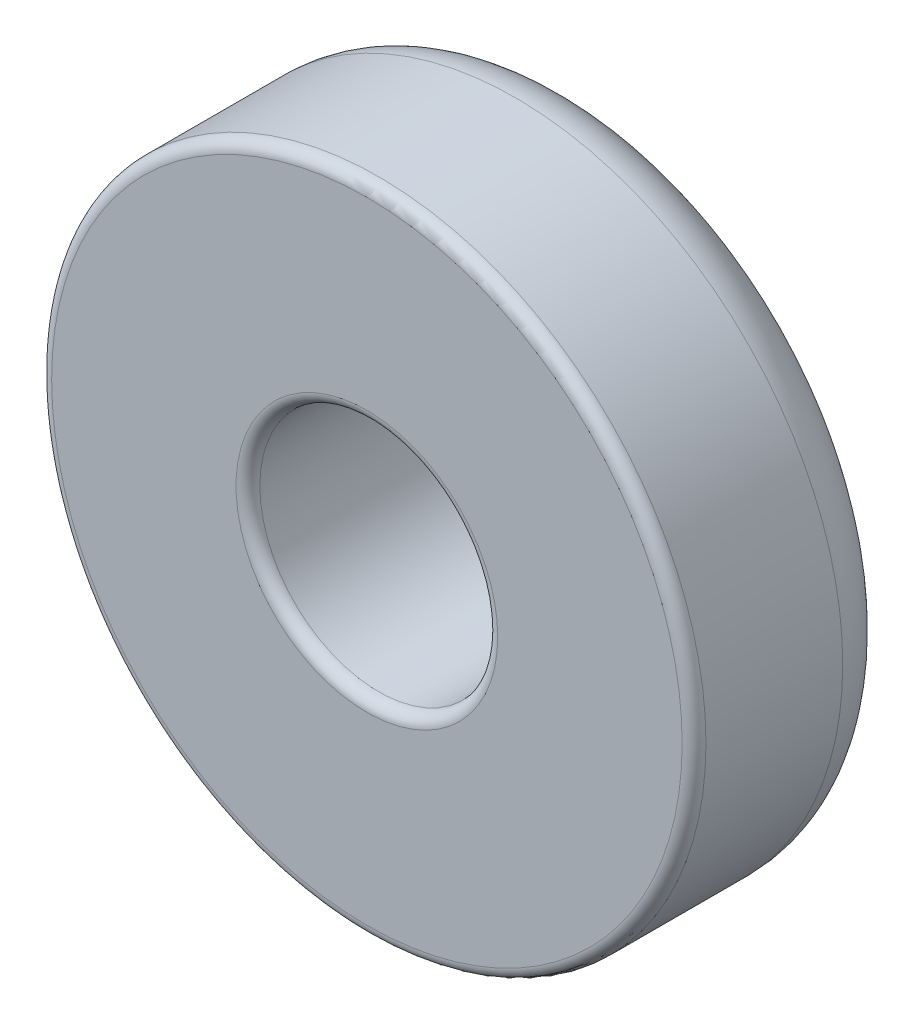
from build123d import *

# Parameters (mm, degrees)
SKETCH1_R           = 2.75
SKETCH1_R_2         = 1
EXTRUDE_THIN1_DEPTH = 1.75
FILLET1_R           = 0.5
FILLET2_R           = 0.1
FILLET3_R           = 0.1


with BuildPart() as part:
    # Sketch1 → Extrude-Thin1 (new body)
    with BuildSketch(Plane.XY):
        Circle(SKETCH1_R)
        Circle(SKETCH1_R_2, mode=Mode.SUBTRACT)
    extrude(amount=EXTRUDE_THIN1_DEPTH)

    # Fillet1
    fillet1_edges = [part.edges().sort_by_distance(p)[0] for p in [
        (-2.75, 0, 0),
    ]]
    fillet(fillet1_edges, radius=FILLET1_R)

    # Fillet2
    fillet2_edges = [part.edges().sort_by_distance(p)[0] for p in [
        (-2.75, 0, 1.75),
        (-1, 0, 1.75),
    ]]
    fillet(fillet2_edges, radius=FILLET2_R)

    # Fillet3
    fillet3_edges = [part.edges().sort_by_distance(p)[0] for p in [
        (-1, 0, 0),
    ]]
    fillet(fillet3_edges, radius=FILLET3_R)


solid = part.part
